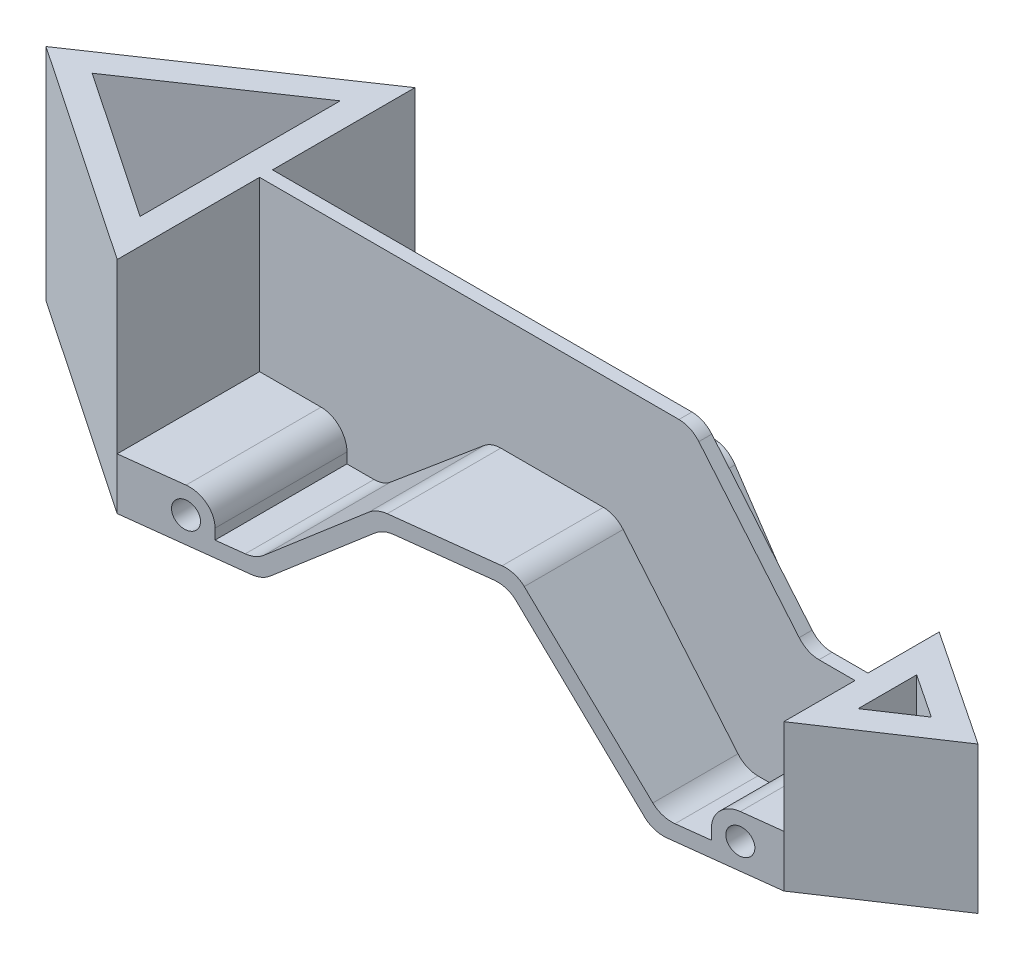
from build123d import *

# Parameters (mm, degrees)
BOSS_EXTRUDE1_DEPTH     = 85
SKETCH3_R               = 5
BOSS_EXTRUDE2_DEPTH     = 57.5
BOSS_EXTRUDE3_START     = -25
BOSS_EXTRUDE3_DEPTH     = 56.666666667
BOSS_EXTRUDE4_DEPTH     = 2.5
FILLET2_R               = 10
CUT_EXTRUDE1_DEPTH      = 86
CUT_EXTRUDE1_DEPTH_BACK = 26


with BuildPart() as part:
    # Sketch2 → Boss-Extrude1 (new body)
    with BuildSketch(Plane(origin=(0, 0, 0), x_dir=(1, 0, 0), z_dir=(0, 1, 0))):
        Polygon((0, -57.5), (0, 57.5), (-85, 0), align=None)
        Polygon((-10, 38.662131911), (-67.152716738, 0), (-10, -38.662131911), align=None, mode=Mode.SUBTRACT)
    extrude(amount=BOSS_EXTRUDE1_DEPTH)

    # Sketch3 → Boss-Extrude2 (add, symmetric)
    with BuildSketch(Plane.XY):
        with BuildLine():
            Line((0, 0), (50, 0))
            Line((50, 0), (91.711375741, 35))
            Line((91.711375741, 35), (134.654022129, 35))
            Line((134.654022129, 35), (185, -25))
            Line((185, -25), (230, -25))
            Line((230, -25), (230, -19))
            Line((230, -19), (230, -5))
            Line((230, -5), (215, -5))
            ThreePointArc((215, -5), (207.928932188, -7.928932188), (205, -15))
            Line((205, -15), (205, -19))
            Line((205, -19), (187.797845949, -19))
            Line((187.797845949, -19), (137.451868078, 41))
            Line((137.451868078, 41), (89.527554335, 41))
            Line((89.527554335, 41), (47.816178594, 6))
            Line((47.816178594, 6), (33.75, 6))
            Line((33.75, 6), (33.75, 10))
            ThreePointArc((33.75, 10), (30.821067812, 17.071067812), (23.75, 20))
            Line((23.75, 20), (0, 20))
            Line((0, 20), (0, 0))
        make_face()
        with Locations((23.75, 10)):
            Circle(SKETCH3_R, mode=Mode.SUBTRACT)
        with Locations((215, -15)):
            Circle(SKETCH3_R, mode=Mode.SUBTRACT)
    extrude(amount=BOSS_EXTRUDE2_DEPTH, both=True)

    # Sketch4 → Boss-Extrude3 (add)
    with BuildSketch(Plane(origin=(0, 0, 0), x_dir=(1, 0, 0), z_dir=(0, 1, 0)).offset(BOSS_EXTRUDE3_START)):
        Polygon((230, -30), (230, 30), (275, 0), align=None)
        Polygon((240, 11.314829082), (256.972243623, 0), (240, -11.314829082), align=None, mode=Mode.SUBTRACT)
    extrude(amount=BOSS_EXTRUDE3_DEPTH)

    # Sketch5 → Boss-Extrude4 (add, symmetric)
    with BuildSketch(Plane.XY):
        with BuildLine():
            Line((0, 85), (166.672120299, 85))
            Line((166.672120299, 85), (211.424100629, 31.666666667))
            Line((211.424100629, 31.666666667), (230, 31.666666667))
            Line((230, 31.666666667), (230, -5))
            Line((230, -5), (215, -5))
            ThreePointArc((215, -5), (207.928932188, -7.928932188), (205, -15))
            Line((205, -15), (205, -19))
            Line((205, -19), (187.797845949, -19))
            Line((187.797845949, -19), (137.451868078, 41))
            Line((137.451868078, 41), (89.527554335, 41))
            Line((89.527554335, 41), (47.816178594, 6))
            Line((47.816178594, 6), (33.75, 6))
            Line((33.75, 6), (33.75, 10))
            ThreePointArc((33.75, 10), (30.821067812, 17.071067812), (23.75, 20))
            Line((23.75, 20), (0, 20))
            Line((0, 20), (0, 85))
        make_face()
    extrude(amount=BOSS_EXTRUDE4_DEPTH, both=True)

    # Fillet2
    fillet2_edges = [part.edges().sort_by_distance(p)[0] for p in [
        (211.424100629, 31.666666667, 0),
        (166.672120299, 85, 0),
        (50, 0, 0),
        (91.711375741, 35, 0),
        (134.654022129, 35, 0),
        (185, -25, 0),
        (187.797845949, -19, 30),
        (137.451868078, 41, 30),
        (89.527554335, 41, 30),
        (47.816178594, 6, 30),
        (47.816178594, 6, -30),
        (89.527554335, 41, -30),
        (137.451868078, 41, -30),
        (187.797845949, -19, -30),
    ]]
    fillet(fillet2_edges, radius=FILLET2_R)

    # Sketch6 → Cut-Extrude1 (cut, two sides)
    with BuildSketch(Plane(origin=(0, 0, 0), x_dir=(1, 0, 0), z_dir=(0, 1, 0))) as cut_extrude1_sk:
        Polygon((0, 57.5), (230, 57.5), (230, 30), align=None)
        Polygon((0, -57.5), (230, -30), (230, -57.5), align=None)
    extrude(amount=CUT_EXTRUDE1_DEPTH, mode=Mode.SUBTRACT)
    extrude(cut_extrude1_sk.sketch, amount=-CUT_EXTRUDE1_DEPTH_BACK, mode=Mode.SUBTRACT)


solid = part.part
